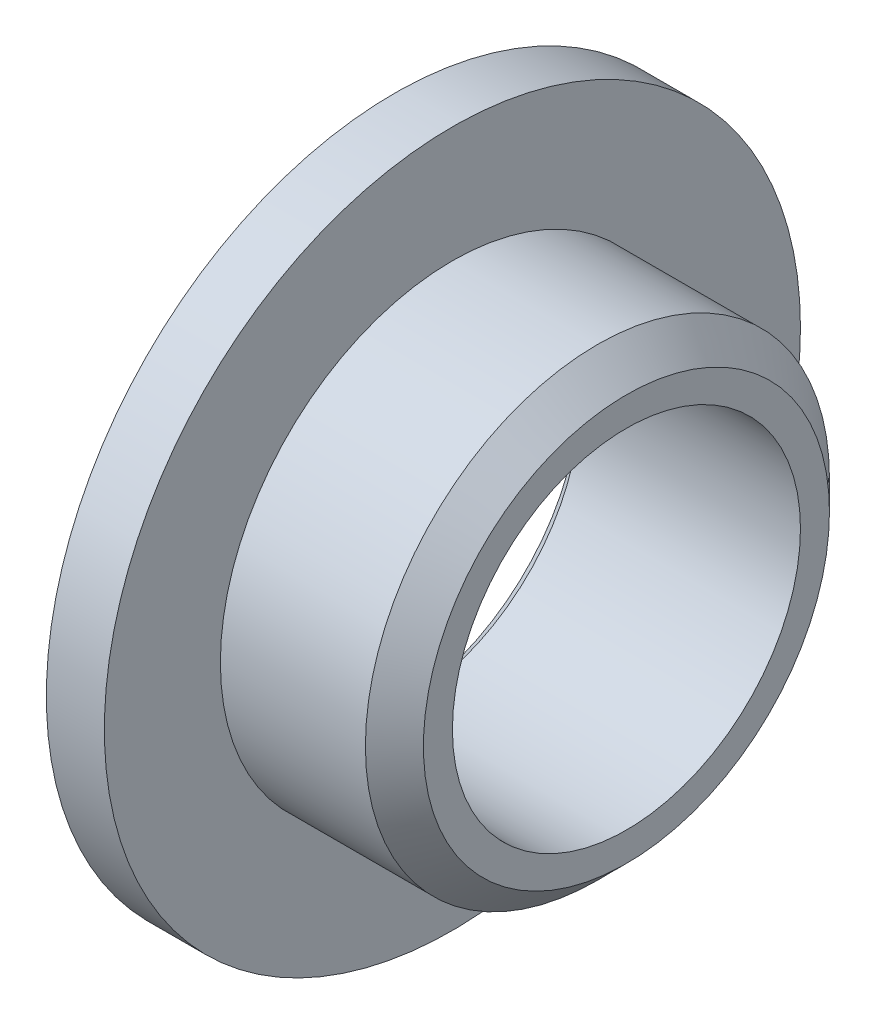
from build123d import *


with BuildPart() as part:
    # Schizzo1 → Rivoluzione1 (revolve)
    with BuildSketch(Plane.XY):
        Polygon((0, 6), (0, 3.2), (0.2, 3), (4, 3), (4, 3.5), (3.5, 4), (1, 4), (1, 6), align=None)
    revolve(axis=Axis((0, 0, 0), (1, 0, 0)))


solid = part.part
